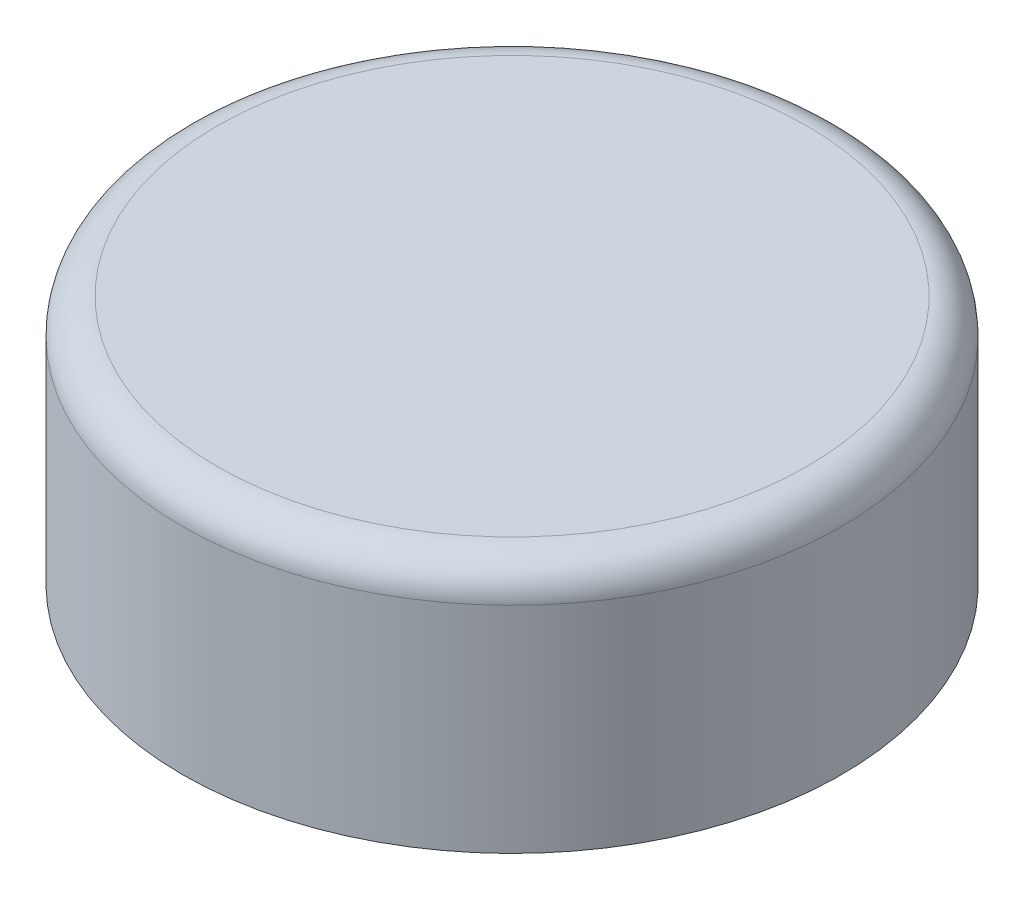
from build123d import *

# Parameters (mm, degrees)
SKETCH1_R      = 30.187952918
EXTRUDE1_DEPTH = 22.86
FILLET2_R      = 3.175


with BuildPart() as part:
    # Sketch1 → Extrude1 (new body)
    with BuildSketch(Plane(origin=(0, 0, 0), x_dir=(1, 0, 0), z_dir=(0, 1, 0))):
        with Locations(Location((0, 0, 0), (0, 0, 270))):  # turned: the seam where the file's is
            Circle(SKETCH1_R)
    extrude(amount=EXTRUDE1_DEPTH)

    # Fillet2
    fillet2_edges = [part.edges().sort_by_distance(p)[0] for p in [
        (0, 22.86, -30.187952918),
    ]]
    fillet(fillet2_edges, radius=FILLET2_R)


solid = part.part
